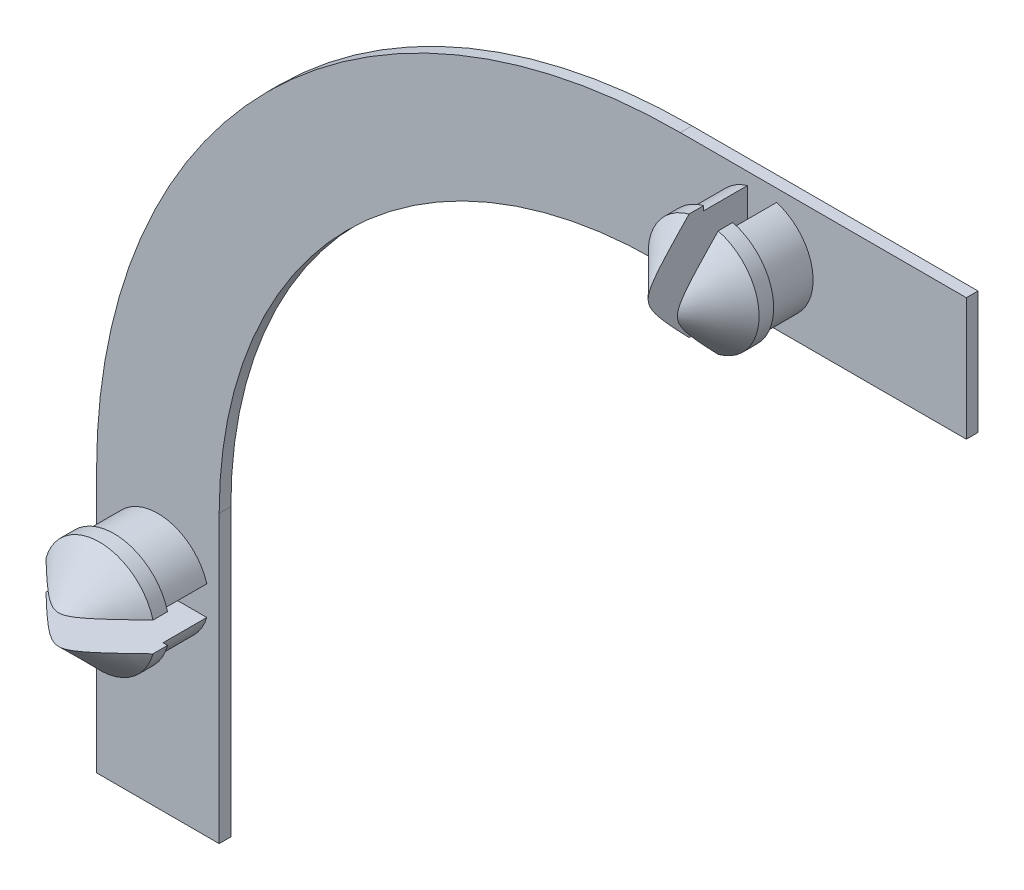
from build123d import *

# Parameters (mm, degrees)
SKICA2_W                 = 29.8
SKICA2_H                 = 4.2
P_IDAT_VYSUNUT_M2_DEPTH  = 0.4
SKICA3_R                 = 1.75
P_IDAT_VYSUNUT_M3_DEPTH  = 1.5
SKICA5_R                 = 1.9
P_IDAT_VYSUNUT_M5_DEPTH  = 2
ZKOSEN_2_SIZE            = 1.5
SKICA7_W                 = 1
SKICA7_H                 = 5
ODEBRAT_VYSUNUT_M1_DEPTH = 3.5
SKICA8_W                 = 4.2
SKICA8_H                 = 24.8
P_IDAT_VYSUNUT_M6_DEPTH  = 0.4
SKICA9_R                 = 1.75
P_IDAT_VYSUNUT_M7_DEPTH  = 1.5
SKICA10_R                = 1.9
P_IDAT_VYSUNUT_M8_DEPTH  = 2
ZKOSEN_3_SIZE            = 1.5
SKICA12_W                = 5
SKICA12_H                = 1
ODEBRAT_VYSUNUT_M2_DEPTH = 3.5
ZAOBLIT1_R               = 15
ZAOBLIT2_R               = 20


with BuildPart() as part:
    # Skica2 → Přidat vysunutím2 (new body)
    with BuildSketch(Plane.XY):
        Rectangle(SKICA2_W, SKICA2_H)
    extrude(amount=P_IDAT_VYSUNUT_M2_DEPTH)

    # Skica3 → Přidat vysunutím3 (add)
    with BuildSketch(Plane.XY.offset(0.4)):
        with Locations((7.9, 0)):
            Circle(SKICA3_R)
    extrude(amount=P_IDAT_VYSUNUT_M3_DEPTH)

    # Skica5 → Přidat vysunutím5 (add)
    with BuildSketch(Plane.XY.offset(1.9)):
        with Locations((7.9, 0)):
            Circle(SKICA5_R)
    extrude(amount=P_IDAT_VYSUNUT_M5_DEPTH)

    # Zkosení2
    zkosen_2_edges = [part.edges().sort_by_distance(p)[0] for p in [
        (6, 0, 3.9),
    ]]
    chamfer(zkosen_2_edges, length=ZKOSEN_2_SIZE)

    # Skica7 → Odebrat vysunutím1 (cut)
    with BuildSketch(Plane.XY.offset(3.9)):
        with Locations((7.9, 0)):
            Rectangle(SKICA7_W, SKICA7_H)
    extrude(amount=-ODEBRAT_VYSUNUT_M1_DEPTH, mode=Mode.SUBTRACT)

    # Skica8 → Přidat vysunutím6 (add)
    with BuildSketch(Plane(origin=(0, 0, 0), x_dir=(-1, 0, 0), z_dir=(0, 0, -1))):
        with Locations((12.8, -14.5)):
            Rectangle(SKICA8_W, SKICA8_H)
    extrude(amount=-P_IDAT_VYSUNUT_M6_DEPTH)

    # Skica9 → Přidat vysunutím7 (add)
    with BuildSketch(Plane.XY.offset(0.4)):
        with Locations((-12.8, -19.9)):
            Circle(SKICA9_R)
    extrude(amount=P_IDAT_VYSUNUT_M7_DEPTH)

    # Skica10 → Přidat vysunutím8 (add)
    with BuildSketch(Plane.XY.offset(1.9)):
        with Locations((-12.8, -19.9)):
            Circle(SKICA10_R)
    extrude(amount=P_IDAT_VYSUNUT_M8_DEPTH)

    # Zkosení3
    zkosen_3_edges = [part.edges().sort_by_distance(p)[0] for p in [
        (-14.7, -19.9, 3.9),
    ]]
    chamfer(zkosen_3_edges, length=ZKOSEN_3_SIZE)

    # Skica12 → Odebrat vysunutím2 (cut)
    with BuildSketch(Plane.XY.offset(3.9)):
        with Locations((-12.8, -19.9)):
            Rectangle(SKICA12_W, SKICA12_H)
    extrude(amount=-ODEBRAT_VYSUNUT_M2_DEPTH, mode=Mode.SUBTRACT)

    # Zaoblit1
    zaoblit1_edges = [part.edges().sort_by_distance(p)[0] for p in [
        (-10.7, -2.1, 0.2),
    ]]
    fillet(zaoblit1_edges, radius=ZAOBLIT1_R)

    # Zaoblit2
    zaoblit2_edges = [part.edges().sort_by_distance(p)[0] for p in [
        (-14.9, 2.1, 0.2),
    ]]
    fillet(zaoblit2_edges, radius=ZAOBLIT2_R)


solid = part.part
